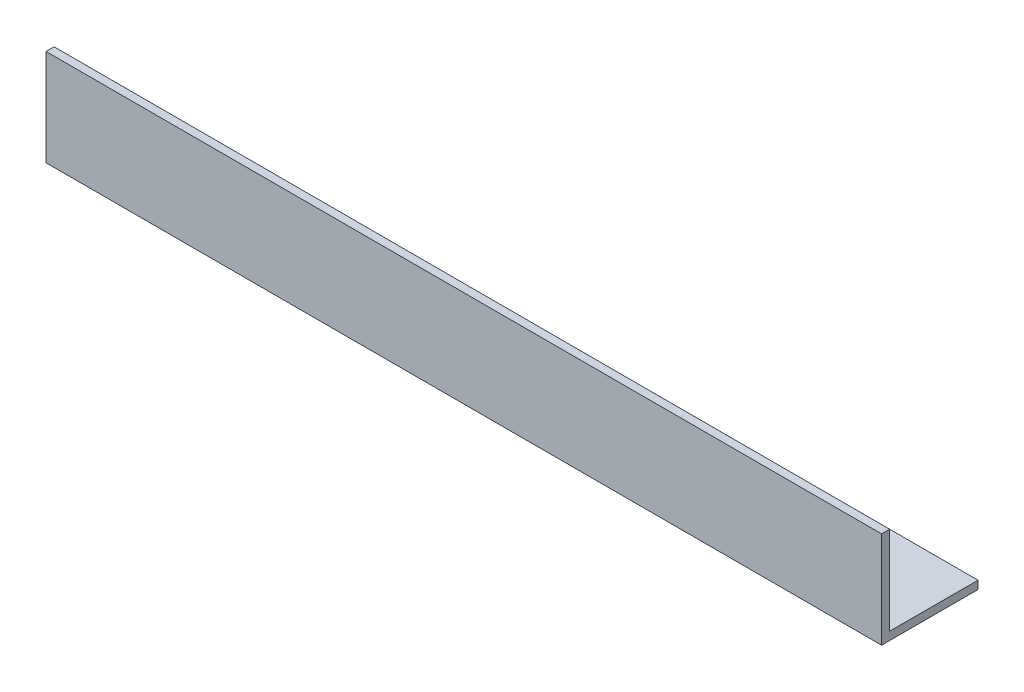
from build123d import *

# Parameters (mm, degrees)
BOSS_EXTRUDE1_DEPTH = 165.1


with BuildPart() as part:
    # Sketch1 → Boss-Extrude1 (new body)
    with BuildSketch(Plane(origin=(0, 0, 0), x_dir=(0, 0, -1), z_dir=(1, 0, 0))):
        Polygon((0, 0), (0, 19.05), (1.6002, 19.05), (1.6002, 1.6002), (19.05, 1.6002), (19.05, 0), align=None)
    extrude(amount=BOSS_EXTRUDE1_DEPTH)


solid = part.part
